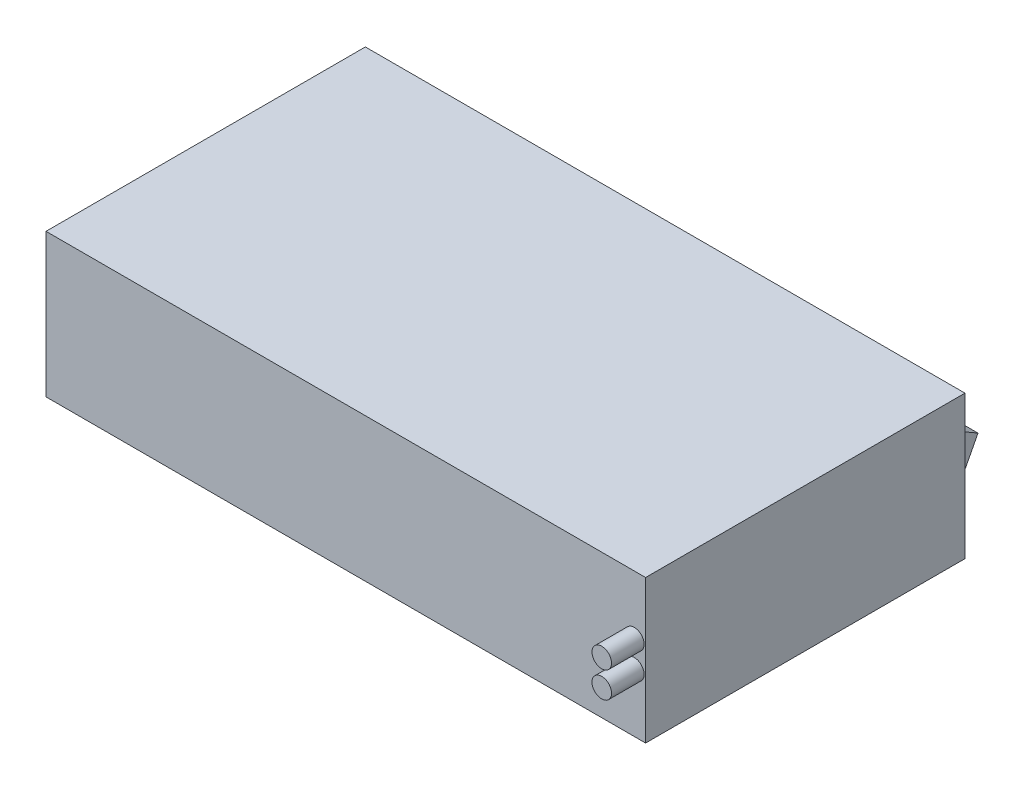
from build123d import *

# Parameters (mm, degrees)
SKETCH_1_W          = 92
SKETCH_1_H          = 49
EXTRUDE_1_DEPTH     = 22
SKETCH_2_W          = 6
SKETCH_2_H          = 10
EXTRUDE_2_DEPTH     = 4
CUT_EXTRUDE_2_DEPTH = 91
SKETCH_5_R          = 1.5
EXTRUDE_3_DEPTH     = 5


with BuildPart() as part:
    # 草图1 → 凸台-拉伸1 (new body)
    with BuildSketch(Plane(origin=(0, 0, 0), x_dir=(1, 0, 0), z_dir=(0, 1, 0))):
        with Locations((-1.545219638, 10.208010336)):
            Rectangle(SKETCH_1_W, SKETCH_1_H)
    extrude(amount=EXTRUDE_1_DEPTH)

    # 草图2 → 凸台-拉伸2 (add)
    with BuildSketch(Plane(origin=(0, 0, -34.708010336), x_dir=(-1, 0, 0), z_dir=(0, 0, -1))):
        with Locations((-39.454780362, 11)):
            Rectangle(SKETCH_2_W, SKETCH_2_H)
    extrude(amount=EXTRUDE_2_DEPTH)

    # 草图3 → 切除-拉伸2 (cut, through all)
    with BuildSketch(Plane(origin=(42.454780362, 0, 0), x_dir=(0, 0, -1), z_dir=(1, 0, 0))):
        Polygon((38.708010336, 16), (34.708010336, 16), (38.708010336, 13.690598923), align=None)
        Polygon((38.708010336, 13.690598923), (34.708010336, 6), (38.708010336, 6), align=None)
    extrude(amount=-CUT_EXTRUDE_2_DEPTH, mode=Mode.SUBTRACT)

    # 草图4 → 旋转1 (revolve)
    with BuildSketch(Plane(origin=(0, 0, -34.708010336), x_dir=(-1, 0, 0), z_dir=(0, 0, -1))):
        with BuildLine():
            Line((-34.454780362, 11), (-34.454780362, 12))
            ThreePointArc((-34.454780362, 12), (-33.454780362, 11), (-34.454780362, 10))
            Line((-34.454780362, 10), (-34.454780362, 11))
        make_face()
    revolve(axis=Axis((34.454780362, 11, -34.708010336), (0, 1, 0)))

    # 草图5 → 凸台-拉伸3 (add)
    with BuildSketch(Plane.XY.offset(14.291989664)):
        with Locations((42.72658272, 13)):
            Circle(SKETCH_5_R)
        with Locations((42.72658272, 9)):
            Circle(SKETCH_5_R)
    extrude(amount=EXTRUDE_3_DEPTH)


solid = part.part
